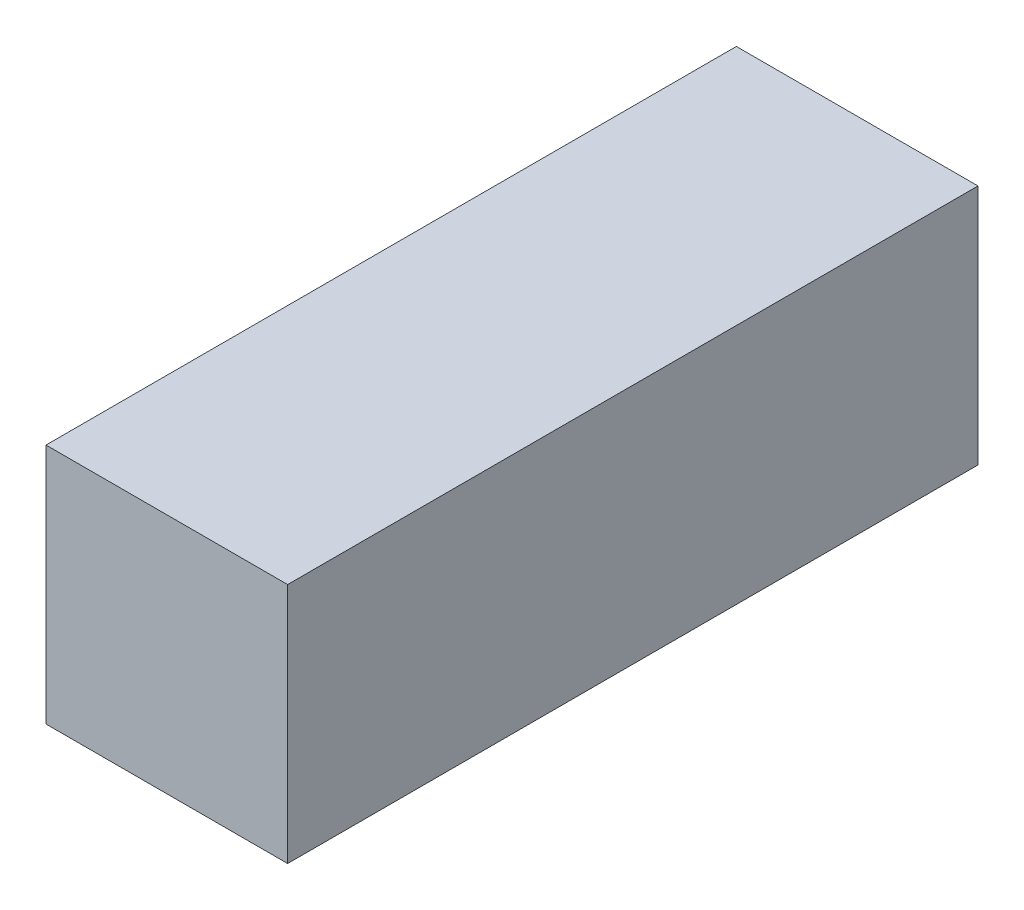
from build123d import *

# Parameters (mm, degrees)
SKETCH1_W           = 7
SKETCH1_H           = 7
BOSS_EXTRUDE1_DEPTH = 20


with BuildPart() as part:
    # Sketch1 → Boss-Extrude1 (new body)
    with BuildSketch(Plane.XY):
        with Locations((3.5, 3.5)):
            Rectangle(SKETCH1_W, SKETCH1_H)
    extrude(amount=BOSS_EXTRUDE1_DEPTH)


solid = part.part
